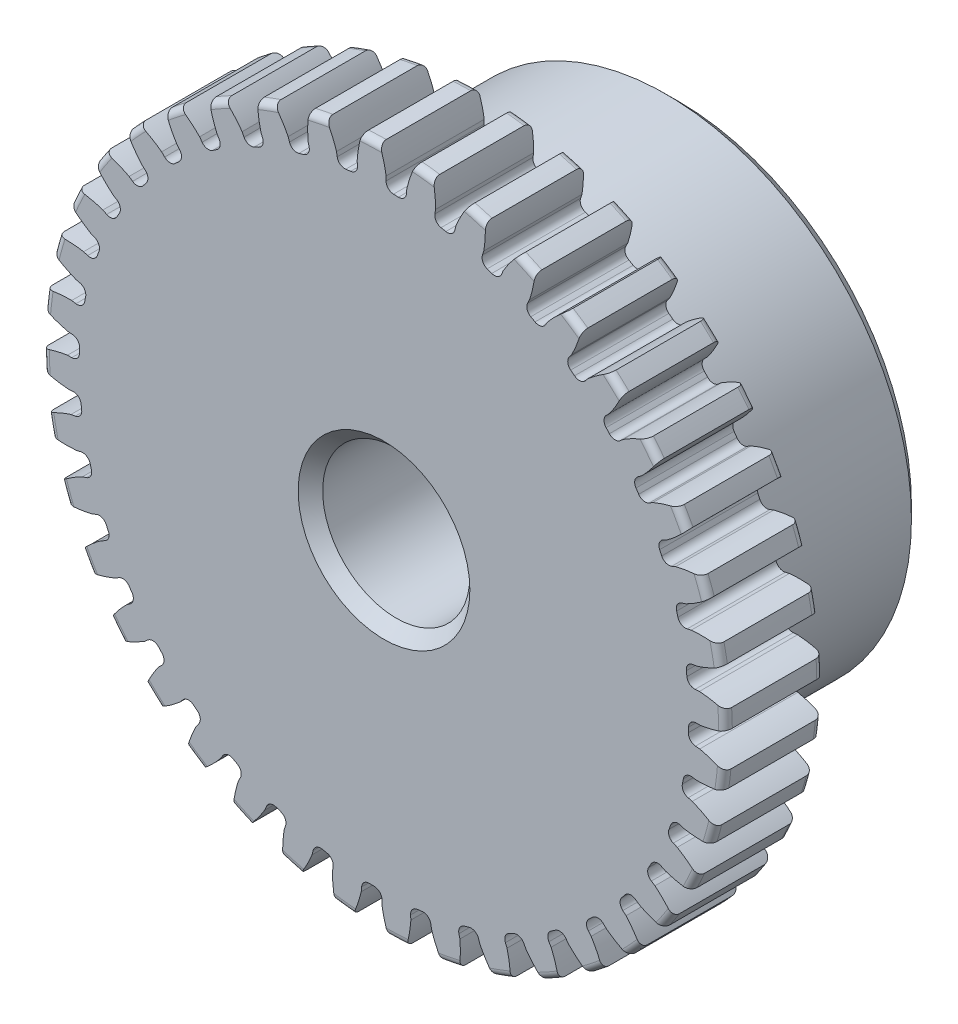
from build123d import *

# Parameters (mm, degrees)
SKETCH1_R                = 11.049
BOSS_EXTRUDE1_DEPTH      = 3.175
SKETCH2_W                = 6.35
SKETCH2_H                = 7.9375
FILLET2_R                = 0.22098
CUT_EXTRUDE1_DEPTH       = 10.525
FILLET1_R                = 0.249264754
CIRPATTERN1_COUNT        = 40
FILLET1_OF_CIRPATTERN1_R = 0.249264754
SKETCH5_R                = 2.38125
CUT_EXTRUDE2_DEPTH       = 10.525
CHAMFER1_SIZE            = 0.396875


with BuildPart() as part:
    # Sketch1 → Boss-Extrude1 (new body)
    with BuildSketch(Plane.XY):
        Circle(SKETCH1_R)
    extrude(amount=-BOSS_EXTRUDE1_DEPTH)

    # Sketch2 → Revolve1 (revolve)
    with BuildSketch(Plane(origin=(0, 0, 0), x_dir=(0, 0, -1), z_dir=(1, 0, 0))):
        with Locations((6.35, 3.96875)):
            Rectangle(SKETCH2_W, SKETCH2_H)
    revolve(axis=Axis((0, 0, -3.175), (0, 0, -1)))

    # Fillet2
    fillet2_edges = [part.edges().sort_by_distance(p)[0] for p in [
        (-11.049, 0, 0),
        (-11.049, 0, -3.175),
        (0, -7.9375, -3.175),
    ]]
    fillet(fillet2_edges, radius=FILLET2_R)

    # Sketch4 → Cut-Extrude1 (cut, through all)
    with BuildSketch(Plane.XY):
        with BuildLine():
            Line((0.06644077, 10.241915199), (0.06644077, 9.858627369))
            ThreePointArc((0.06644077, 9.858627369), (0.387057588, 9.851250397), (0.707264839, 9.833449263))
            Line((0.707264839, 9.833449263), (0.737337326, 10.21555554))
            add(Edge.make_bspline(
                [(2.029373988, 12.311283477), (1.018355203, 11.423081891), (0.737337326, 10.21555554)],
                knots=[0, 0, 0, 1, 1, 1], degree=2))
            ThreePointArc((2.029373988, 12.311283477), (0.489862434, 12.46780231), (-1.057183653, 12.432554941))
            add(Edge.make_bspline(
                [(-1.057183653, 12.432554941), (-0.118969172, 11.467767592), (0.06644077, 10.241915199)],
                knots=[0, 0, 0, 1, 1, 1], degree=2))
        make_face()
    cut_extrude1 = extrude(amount=-CUT_EXTRUDE1_DEPTH, mode=Mode.SUBTRACT)

    # Fillet1
    fillet1_edges = [part.edges().sort_by_distance(p)[0] for p in [
        (0.707264839, 9.833449263, -1.5875),
        (0.06644077, 9.858627369, -1.5875),
    ]]
    fillet(fillet1_edges, radius=FILLET1_R)

    # CirPattern1: Cut-Extrude1 ×40 about axis
    cirpattern1_axis = Axis((0, 0, -3.175), (0, 0, 1))
    for i in range(1, CIRPATTERN1_COUNT):
        add(cut_extrude1.rotate(cirpattern1_axis, i * 360 / CIRPATTERN1_COUNT), mode=Mode.SUBTRACT)

    # Fillet1 of CirPattern1
    fillet1_of_cirpattern1_edges = [part.edges().sort_by_distance(p)[0] for p in [
        (-0.83973314, 9.823023782, -1.5875),
        (-1.476606324, 9.747644933, -1.5875),
        (-2.366054102, 9.570722854, -1.5875),
        (-2.983294471, 9.396643128, -1.5875),
        (-3.83411496, 9.082758967, -1.5875),
        (-4.416524006, 8.814264784, -1.5875),
        (-5.207767182, 8.371147409, -1.5875),
        (-5.741004063, 8.014849987, -1.5875),
        (-6.453186893, 7.45341042, -1.5875),
        (-6.924121546, 7.018082985, -1.5875),
        (-7.539707726, 6.35214573, -1.5875),
        (-7.936744177, 5.848507487, -1.5875),
        (-8.440575931, 5.094470131, -1.5875),
        (-8.753937826, 4.534922326, -1.5875),
        (-9.133609145, 3.711351769, -1.5875),
        (-9.355580474, 3.109672326, -1.5875),
        (-9.601742589, 2.23684761, -1.5875),
        (-9.72685768, 1.607851873, -1.5875),
        (-9.833449263, 0.707264839, -1.5875),
        (-9.858627369, 0.06644077, -1.5875),
        (-9.823023782, -0.83973314, -1.5875),
        (-9.747644933, -1.476606324, -1.5875),
        (-9.570722854, -2.366054102, -1.5875),
        (-9.396643128, -2.983294471, -1.5875),
        (-9.082758967, -3.83411496, -1.5875),
        (-8.814264784, -4.416524006, -1.5875),
        (-8.371147409, -5.207767182, -1.5875),
        (-8.014849987, -5.741004063, -1.5875),
        (-7.45341042, -6.453186893, -1.5875),
        (-7.018082985, -6.924121546, -1.5875),
        (-6.35214573, -7.539707726, -1.5875),
        (-5.848507487, -7.936744177, -1.5875),
        (-5.094470131, -8.440575931, -1.5875),
        (-4.534922326, -8.753937826, -1.5875),
        (-3.711351769, -9.133609145, -1.5875),
        (-3.109672326, -9.355580474, -1.5875),
        (-2.23684761, -9.601742589, -1.5875),
        (-1.607851873, -9.72685768, -1.5875),
        (-0.707264839, -9.833449263, -1.5875),
        (-0.06644077, -9.858627369, -1.5875),
        (0.83973314, -9.823023782, -1.5875),
        (1.476606324, -9.747644933, -1.5875),
        (2.366054102, -9.570722854, -1.5875),
        (2.983294471, -9.396643128, -1.5875),
        (3.83411496, -9.082758967, -1.5875),
        (4.416524006, -8.814264784, -1.5875),
        (5.207767182, -8.371147409, -1.5875),
        (5.741004063, -8.014849987, -1.5875),
        (6.453186893, -7.45341042, -1.5875),
        (6.924121546, -7.018082985, -1.5875),
        (7.539707726, -6.35214573, -1.5875),
        (7.936744177, -5.848507487, -1.5875),
        (8.440575931, -5.094470131, -1.5875),
        (8.753937826, -4.534922326, -1.5875),
        (9.133609145, -3.711351769, -1.5875),
        (9.355580474, -3.109672326, -1.5875),
        (9.601742589, -2.23684761, -1.5875),
        (9.72685768, -1.607851873, -1.5875),
        (9.833449263, -0.707264839, -1.5875),
        (9.858627369, -0.06644077, -1.5875),
        (9.823023782, 0.83973314, -1.5875),
        (9.747644933, 1.476606324, -1.5875),
        (9.570722854, 2.366054102, -1.5875),
        (9.396643128, 2.983294471, -1.5875),
        (9.082758967, 3.83411496, -1.5875),
        (8.814264784, 4.416524006, -1.5875),
        (8.371147409, 5.207767182, -1.5875),
        (8.014849987, 5.741004063, -1.5875),
        (7.45341042, 6.453186893, -1.5875),
        (7.018082985, 6.924121546, -1.5875),
        (6.35214573, 7.539707726, -1.5875),
        (5.848507487, 7.936744177, -1.5875),
        (5.094470131, 8.440575931, -1.5875),
        (4.534922326, 8.753937826, -1.5875),
        (3.711351769, 9.133609145, -1.5875),
        (3.109672326, 9.355580474, -1.5875),
        (2.23684761, 9.601742589, -1.5875),
        (1.607851873, 9.72685768, -1.5875),
    ]]
    fillet(fillet1_of_cirpattern1_edges, radius=FILLET1_OF_CIRPATTERN1_R)

    # Sketch5 → Cut-Extrude2 (cut, through all)
    with BuildSketch(Plane.XY):
        Circle(SKETCH5_R)
    extrude(amount=-CUT_EXTRUDE2_DEPTH, mode=Mode.SUBTRACT)

    # Chamfer1
    chamfer1_edges = [part.edges().sort_by_distance(p)[0] for p in [
        (-2.38125, 0, -9.525),
        (-2.38125, 0, 0),
        (0, -7.9375, -9.525),
    ]]
    chamfer(chamfer1_edges, length=CHAMFER1_SIZE)


solid = part.part
